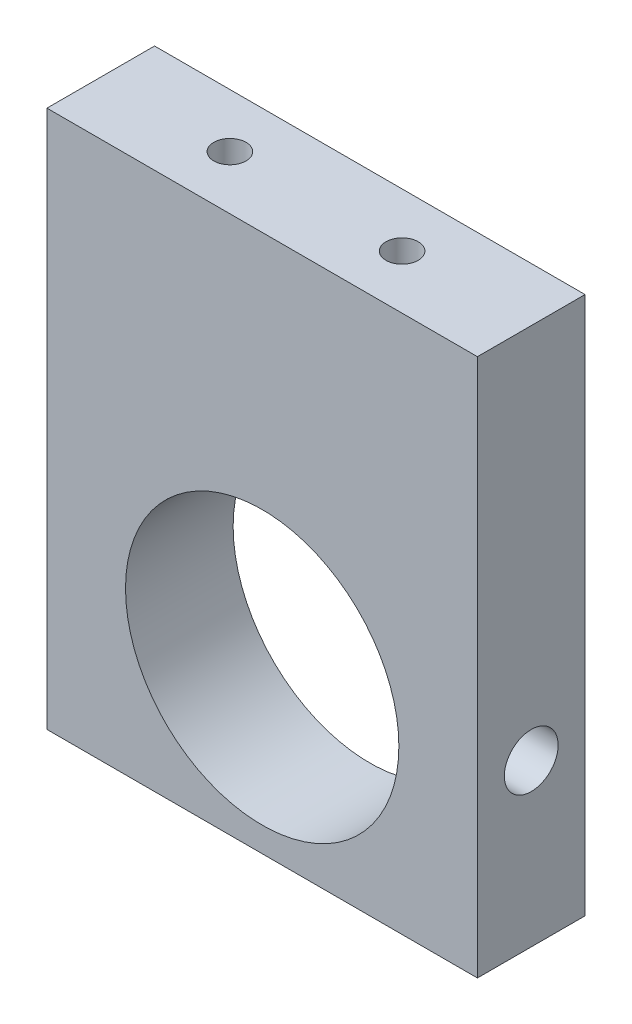
from build123d import *

# Parameters (mm, degrees)
SKETCH1_W           = 20
SKETCH1_H           = 25
BOSS_EXTRUDE1_DEPTH = 5
CUT_EXTRUDE1_REACH  = 7
SKETCH3_R           = 6.35
SKETCH5_R           = 0.75
CUT_EXTRUDE2_DEPTH  = 7
CUT_EXTRUDE3_REACH  = 22
SKETCH6_R           = 1.25


with BuildPart() as part:
    # Sketch1 → Boss-Extrude1 (new body)
    with BuildSketch(Plane.XY):
        with Locations((-14.085851727, 19.333014081)):
            Rectangle(SKETCH1_W, SKETCH1_H)
    extrude(amount=BOSS_EXTRUDE1_DEPTH)

    # Sketch3 → Cut-Extrude1 (cut, up to next)
    with BuildSketch(Plane.XY.offset(5), mode=Mode.PRIVATE) as cut_extrude1_sk1:
        with Locations((-14.085851727, 14.333014081)):
            Circle(SKETCH3_R)
    cut_extrude1_tool1 = extrude(cut_extrude1_sk1.sketch, amount=-CUT_EXTRUDE1_REACH, mode=Mode.PRIVATE) & part.part
    add(cut_extrude1_tool1.solids().sort_by_distance((-14.085852, 14.333014, 5))[0], mode=Mode.SUBTRACT)

    # Sketch5 → Cut-Extrude2 (cut)
    with BuildSketch(Plane(origin=(0, 31.833014081, 0), x_dir=(1, 0, 0), z_dir=(0, 1, 0))):
        with Locations((-10.085851727, -2.5)):
            Circle(SKETCH5_R)
        with Locations((-18.085851727, -2.5)):
            Circle(SKETCH5_R)
    extrude(amount=-CUT_EXTRUDE2_DEPTH, mode=Mode.SUBTRACT)

    # Sketch6 → Cut-Extrude3 (cut, up to next)
    with BuildSketch(Plane(origin=(-4.085851727, 0, 0), x_dir=(0, 0, -1), z_dir=(1, 0, 0)), mode=Mode.PRIVATE) as cut_extrude3_sk1:
        with Locations((-2.5, 14.333014081)):
            Circle(SKETCH6_R)
    cut_extrude3_tool1 = extrude(cut_extrude3_sk1.sketch, amount=-CUT_EXTRUDE3_REACH, mode=Mode.PRIVATE) & part.part
    add(cut_extrude3_tool1.solids().sort_by_distance((-4.085852, 14.333014, 2.5))[0], mode=Mode.SUBTRACT)


solid = part.part
